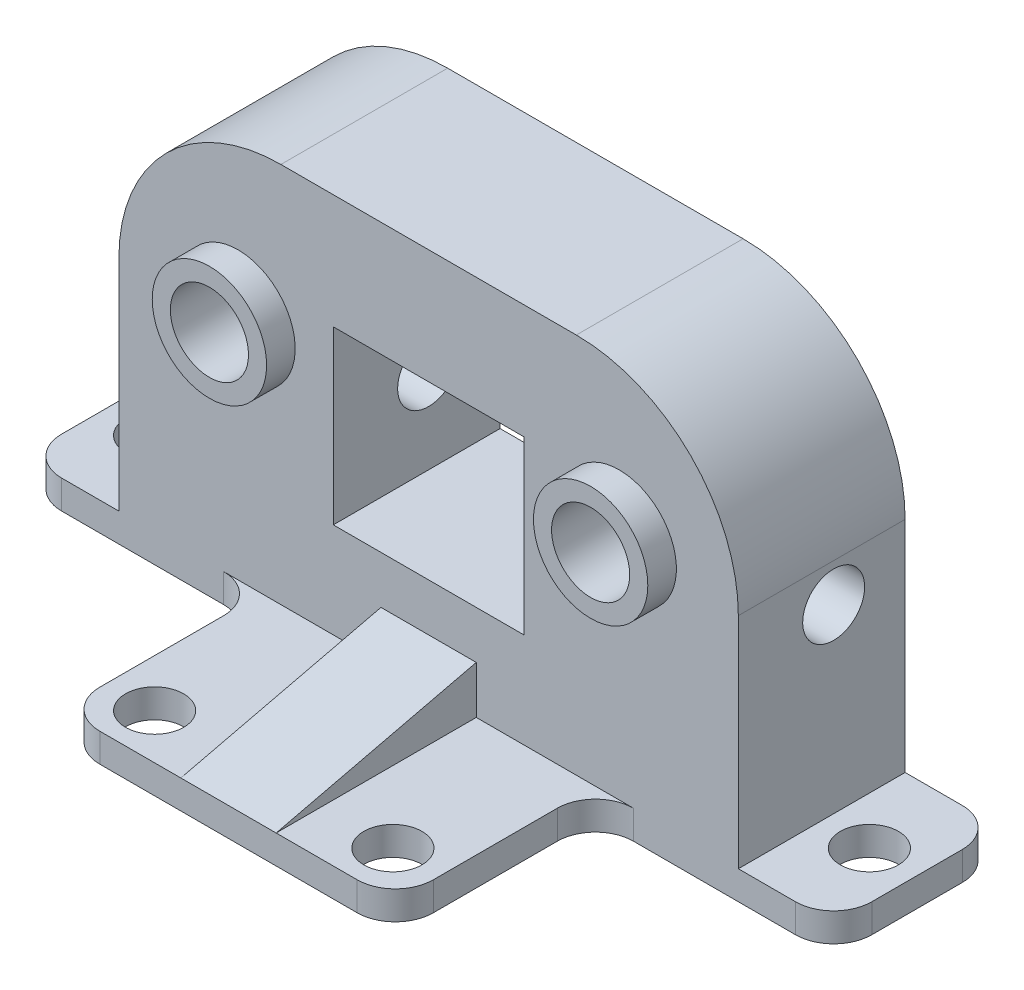
from build123d import *

# Parameters (mm, degrees)
SKICA1_W                 = 85
SKICA1_H                 = 17.5
SKICA1_R                 = 3.05
P_IDAT_VYSUNUT_M1_DEPTH  = 3
SKICA3_W                 = 65
SKICA3_H                 = 40
P_IDAT_VYSUNUT_M2_DEPTH  = 17.5
ZAOBLIT2_R               = 17
SKICA4_R                 = 6
SKICA4_R_2               = 4.1
P_IDAT_VYSUNUT_M3_DEPTH  = 3
ODEBRAT_START            = -4
SKICA4_2_R               = 4.1
ODEBRAT_VYSUNUT_M1_DEPTH = 4
SKICA5_W                 = 20
SKICA5_H                 = 18
ODEBRAT_VYSUNUT_M2_DEPTH = 63.940448044
SKICA7_R                 = 3.25
ODEBRAT_VYSUNUT_M4_DEPTH = 50
SKICA8_W                 = 35
SKICA8_H                 = 21
SKICA8_R                 = 3.05
P_IDAT_VYSUNUT_M4_DEPTH  = 3
ZAOBLIT1_R               = 4
EBRO4_REACH              = 69.382
SKICA12_WALL_W           = 158.350715196
SKICA12_WALL_H           = 10


with BuildPart() as part:
    # Skica1 → P_idat vysunut_m1 (new body)
    with BuildSketch(Plane(origin=(0, 0, 0), x_dir=(1, 0, 0), z_dir=(0, 1, 0))):
        Rectangle(SKICA1_W, SKICA1_H)
        with Locations((-37.5, 0)):
            Circle(SKICA1_R, mode=Mode.SUBTRACT)
        with Locations((37.5, 0)):
            Circle(SKICA1_R, mode=Mode.SUBTRACT)
    extrude(amount=P_IDAT_VYSUNUT_M1_DEPTH)

    # Skica3 → P_idat vysunut_m2 (add)
    with BuildSketch(Plane.XY.offset(8.75)):
        with Locations((0, 23)):
            Rectangle(SKICA3_W, SKICA3_H)
    extrude(amount=-P_IDAT_VYSUNUT_M2_DEPTH)

    # Zaoblit2
    zaoblit2_edges = [part.edges().sort_by_distance(p)[0] for p in [
        (-32.5, 43, 0),
        (32.5, 43, 0),
    ]]
    fillet(zaoblit2_edges, radius=ZAOBLIT2_R)

    # Skica4 → P_idat vysunut_m3 (add)
    # profile 1 of 2: a face of its own
    with BuildSketch(Plane.XY.offset(8.75)):
        with Locations((-20, 27)):
            Circle(SKICA4_R)
        with Locations((-20, 27)):
            Circle(SKICA4_R_2, mode=Mode.SUBTRACT)
    # profile 2 of 2: a face of its own
    with BuildSketch(Plane.XY.offset(8.75)):
        with Locations((20, 27)):
            Circle(SKICA4_R)
        with Locations((20, 27)):
            Circle(SKICA4_R_2, mode=Mode.SUBTRACT)
    extrude(amount=P_IDAT_VYSUNUT_M3_DEPTH)

    # Skica4_2 → Odebrat vysunut_m1 (cut)
    with BuildSketch(Plane.XY.offset(8.75).offset(ODEBRAT_START)):
        with Locations((-20, 27)):
            Circle(SKICA4_2_R)
        with Locations((20, 27)):
            Circle(SKICA4_2_R)
    extrude(amount=ODEBRAT_VYSUNUT_M1_DEPTH, mode=Mode.SUBTRACT)

    # Skica5 → Odebrat vysunut_m2 (cut, through all)
    with BuildSketch(Plane.XY.offset(8.75)):
        with Locations((0, 22)):
            Rectangle(SKICA5_W, SKICA5_H)
    extrude(amount=-ODEBRAT_VYSUNUT_M2_DEPTH, mode=Mode.SUBTRACT)

    # Skica7 → Odebrat vysunut_m4 (cut)
    with BuildSketch(Plane(origin=(32.5, 0, 0), x_dir=(0, 0, -1), z_dir=(1, 0, 0))):
        with Locations((1.25, 22)):
            Circle(SKICA7_R)
    extrude(amount=-ODEBRAT_VYSUNUT_M4_DEPTH, mode=Mode.SUBTRACT)

    # Skica8 → P_idat vysunut_m4 (add)
    with BuildSketch(Plane.XZ):
        with Locations((0, 19.25)):
            Rectangle(SKICA8_W, SKICA8_H)
        with Locations((-12.5, 25)):
            Circle(SKICA8_R, mode=Mode.SUBTRACT)
        with Locations((12.5, 25)):
            Circle(SKICA8_R, mode=Mode.SUBTRACT)
    extrude(amount=-P_IDAT_VYSUNUT_M4_DEPTH)

    # Zaoblit1
    zaoblit1_edges = [part.edges().sort_by_distance(p)[0] for p in [
        (42.5, 1.5, 8.75),
        (42.5, 1.5, -8.75),
        (-42.5, 1.5, -8.75),
        (-42.5, 1.5, 8.75),
        (17.5, 1.5, 8.75),
        (-17.5, 1.5, 8.75),
        (-17.5, 1.5, 29.75),
        (17.5, 1.5, 29.75),
    ]]
    fillet(zaoblit1_edges, radius=ZAOBLIT1_R)

    # Skica12 wall → ebro4 (add, up to next)
    with BuildSketch(Plane(origin=(0, 5.5, 19.25), x_dir=(0, 0.231620527306, -0.972806214685), z_dir=(0, 0.972806214685, 0.231620527306)), mode=Mode.PRIVATE) as ebro4_sk1:
        Rectangle(SKICA12_WALL_W, SKICA12_WALL_H)
    ebro4_tool1 = extrude(ebro4_sk1.sketch, amount=-EBRO4_REACH, mode=Mode.PRIVATE) - part.part
    add(ebro4_tool1.solids().sort_by_distance((0, 5.5, 19.25))[0])


solid = part.part
